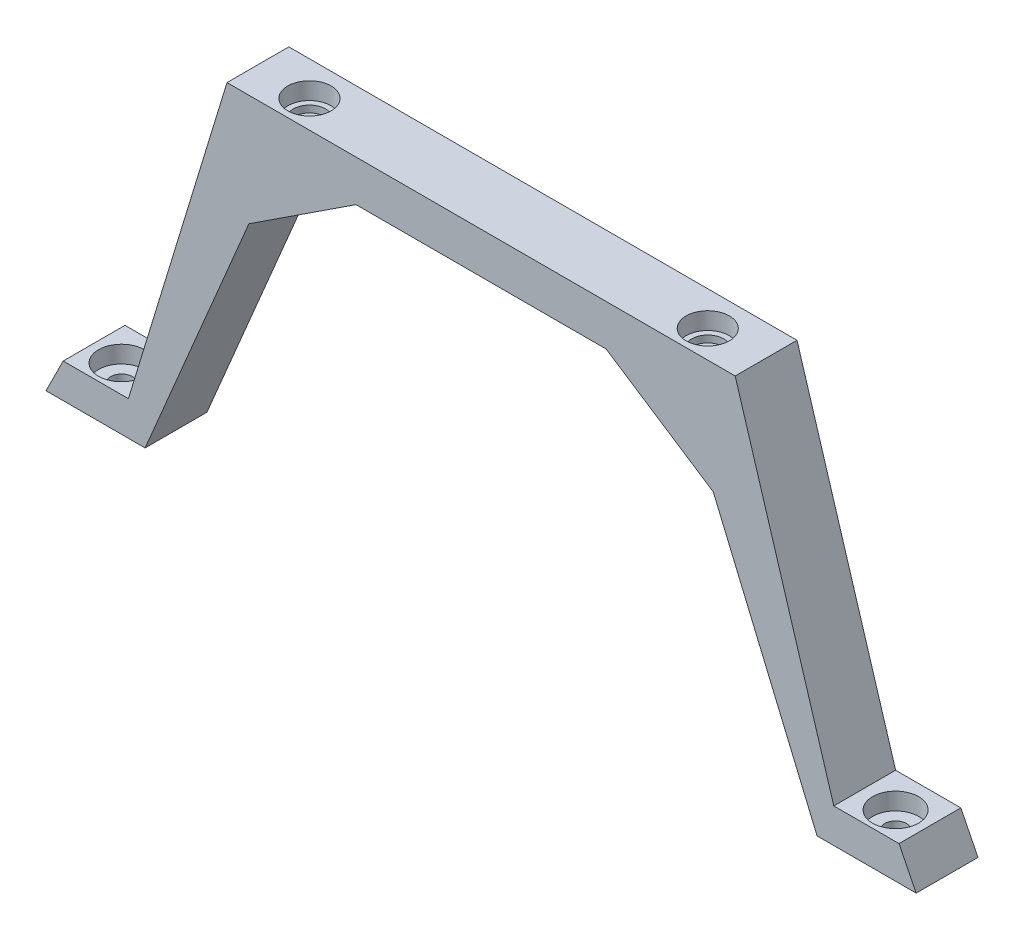
from build123d import *

# Parameters (mm, degrees)
EXTRUDE_1_DEPTH      = 10
SKETCH_7_R           = 1.55
CUT_EXTRUDE_1_DEPTH  = 49.544157215
CUT_EXTRUDE_2_DEPTH  = 8.5
SKETCH_19_W          = 126.714157214
SKETCH_19_H          = 0.99604336
CUT_EXTRUDE_14_DEPTH = 53.044157215
SKETCH_22_R          = 1.575
CUT_EXTRUDE_15_DEPTH = 10
SKETCH_23_R          = 3.35
CUT_EXTRUDE_16_DEPTH = 2.5


with BuildPart() as part:
    # 草图1 → 凸台-拉伸1 (new body)
    with BuildSketch(Plane.XY):
        Polygon((-3.188712924, 13.052848472), (33.811287076, 13.052848472), (33.811287076, 7.052848472), (15.60198174, 7.052848472), (0, -3.158579815), (-15.114428715, -38.991308743), (-29.545791531, -38.991308743), (-27.045791531, -33.991308743), (-17.548712924, -33.991308743), align=None)
    extrude_1 = extrude(amount=EXTRUDE_1_DEPTH)

    # 镜向1: 凸台-拉伸1 across plane
    add(extrude_1.mirror(Plane(origin=(33.811287076, 13.052848472, 10), x_dir=(0, 0, 1), z_dir=(-1, 0, 0))))

    # 草图5 → 切除-旋转7 (revolve, cut)
    with BuildSketch(Plane.XY.offset(5)):
        Polygon((7.961287076, 13.052848472), (7.961287076, 10.552848472), (7.161287076, 10.552848472), (7.161287076, 9.552848472), (6.361287076, 9.552848472), (4.811287076, 9.552848472), (4.811287076, 13.052848472), align=None)
    cut_revolve_7 = revolve(axis=Axis((4.811287076, 9.552848472, 5), (0, 1, 0)), mode=Mode.SUBTRACT)

    # 草图7 → 切除-拉伸1 (cut, through all)
    with BuildSketch(Plane(origin=(0, 9.552848472, 0), x_dir=(1, 0, 0), z_dir=(0, 1, 0))):
        with Locations((4.811287076, -5)):
            Circle(SKETCH_7_R)
    cut_extrude_1 = extrude(amount=-CUT_EXTRUDE_1_DEPTH, mode=Mode.SUBTRACT)

    # 草图8 → 切除-拉伸2 (cut)
    with BuildSketch(Plane(origin=(0, -5.947151528, 0), x_dir=(1, 0, 0), z_dir=(0, 1, 0))):
        Polygon((8.333123718, -5), (6.572205397, -1.95), (3.050368755, -1.95), (1.289450434, -5), (3.050368755, -8.05), (6.572205397, -8.05), align=None)
    cut_extrude_2 = extrude(amount=CUT_EXTRUDE_2_DEPTH, mode=Mode.SUBTRACT)

    # 草图19 → 切除-拉伸14 (cut, through all)
    with BuildSketch(Plane(origin=(0, 13.052848472, 0), x_dir=(1, 0, 0), z_dir=(0, 1, 0))):
        with Locations((33.811287076, -9.50197832)):
            Rectangle(SKETCH_19_W, SKETCH_19_H)
    extrude(amount=-CUT_EXTRUDE_14_DEPTH, mode=Mode.SUBTRACT)

    # 草图22 → 切除-拉伸15 (cut)
    with BuildSketch(Plane(origin=(0, -33.991308743, 0), x_dir=(1, 0, 0), z_dir=(0, 1, 0))):
        with Locations((-22.548712924, -5.00395664)):
            Circle(SKETCH_22_R)
    cut_extrude_15 = extrude(amount=-CUT_EXTRUDE_15_DEPTH, mode=Mode.SUBTRACT)

    # 草图23 → 切除-拉伸16 (cut)
    with BuildSketch(Plane(origin=(0, -33.991308743, 0), x_dir=(1, 0, 0), z_dir=(0, 1, 0))):
        with Locations((-22.548712924, -5.00395664)):
            Circle(SKETCH_23_R)
    cut_extrude_16 = extrude(amount=-CUT_EXTRUDE_16_DEPTH, mode=Mode.SUBTRACT)

    # 镜向2: 切除-旋转7, 切除-拉伸1, 切除-拉伸2, 切除-拉伸15, 切除-拉伸16 across plane
    add(cut_revolve_7.mirror(Plane(origin=(33.811287076, 0, 0), x_dir=(0, 0, 1), z_dir=(1, 0, 0))), mode=Mode.SUBTRACT)
    add(cut_extrude_1.mirror(Plane(origin=(33.811287076, 0, 0), x_dir=(0, 0, 1), z_dir=(1, 0, 0))), mode=Mode.SUBTRACT)
    add(cut_extrude_2.mirror(Plane(origin=(33.811287076, 0, 0), x_dir=(0, 0, 1), z_dir=(1, 0, 0))), mode=Mode.SUBTRACT)
    add(cut_extrude_15.mirror(Plane(origin=(33.811287076, 0, 0), x_dir=(0, 0, 1), z_dir=(1, 0, 0))), mode=Mode.SUBTRACT)
    add(cut_extrude_16.mirror(Plane(origin=(33.811287076, 0, 0), x_dir=(0, 0, 1), z_dir=(1, 0, 0))), mode=Mode.SUBTRACT)


solid = part.part
